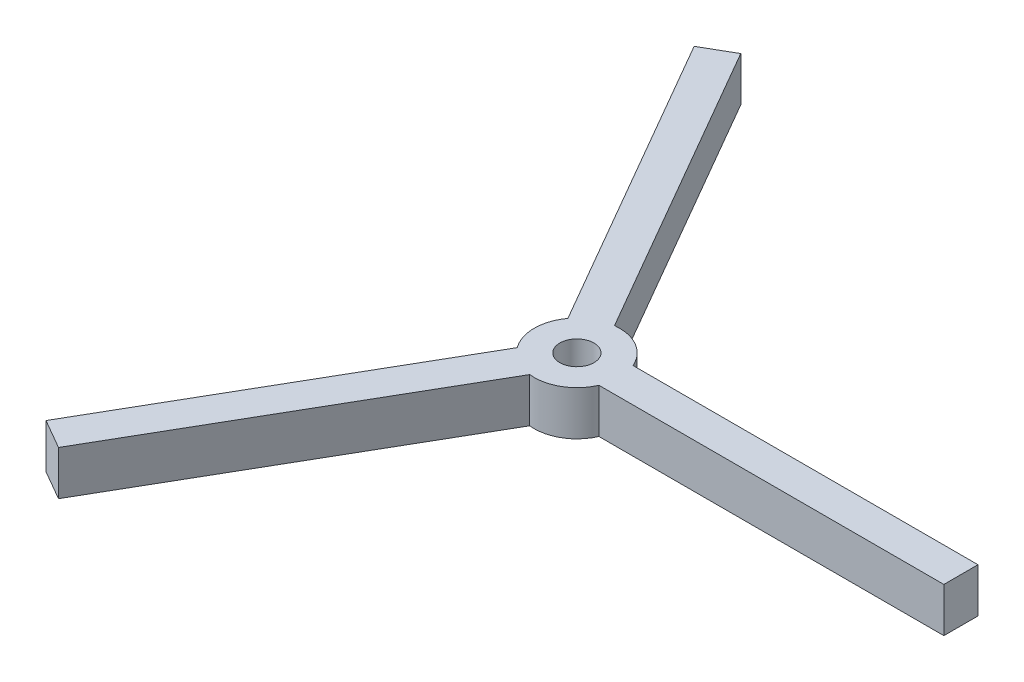
from build123d import *

# Parameters (mm, degrees)
SKETCH1_R           = 6.35
SKETCH1_R_2         = 2.54
BOSS_EXTRUDE1_DEPTH = 6.604
BOSS_EXTRUDE2_START = -0.530129
SKETCH2_W           = 5.08
SKETCH2_H           = 6.604
BOSS_EXTRUDE2_DEPTH = 51.330129
CIRPATTERN1_COUNT   = 3


with BuildPart() as part:
    # Sketch1 → Boss-Extrude1 (new body)
    with BuildSketch(Plane(origin=(0, 0, 0), x_dir=(1, 0, 0), z_dir=(0, 1, 0))):
        Circle(SKETCH1_R)
        Circle(SKETCH1_R_2, mode=Mode.SUBTRACT)
    extrude(amount=BOSS_EXTRUDE1_DEPTH)

    # Sketch2 → Boss-Extrude2 (add)
    with BuildSketch(Plane(origin=(6.35, 0, 0), x_dir=(0, 0, -1), z_dir=(1, 0, 0)).offset(BOSS_EXTRUDE2_START)):
        with Locations((0, 3.302)):
            Rectangle(SKETCH2_W, SKETCH2_H)
    boss_extrude2 = extrude(amount=BOSS_EXTRUDE2_DEPTH)

    # CirPattern1: Boss-Extrude2 ×3 about axis
    cirpattern1_axis = Axis((0, 0, 0), (0, 1, 0))
    for i in range(1, CIRPATTERN1_COUNT):
        add(boss_extrude2.rotate(cirpattern1_axis, i * 360 / CIRPATTERN1_COUNT))


solid = part.part
